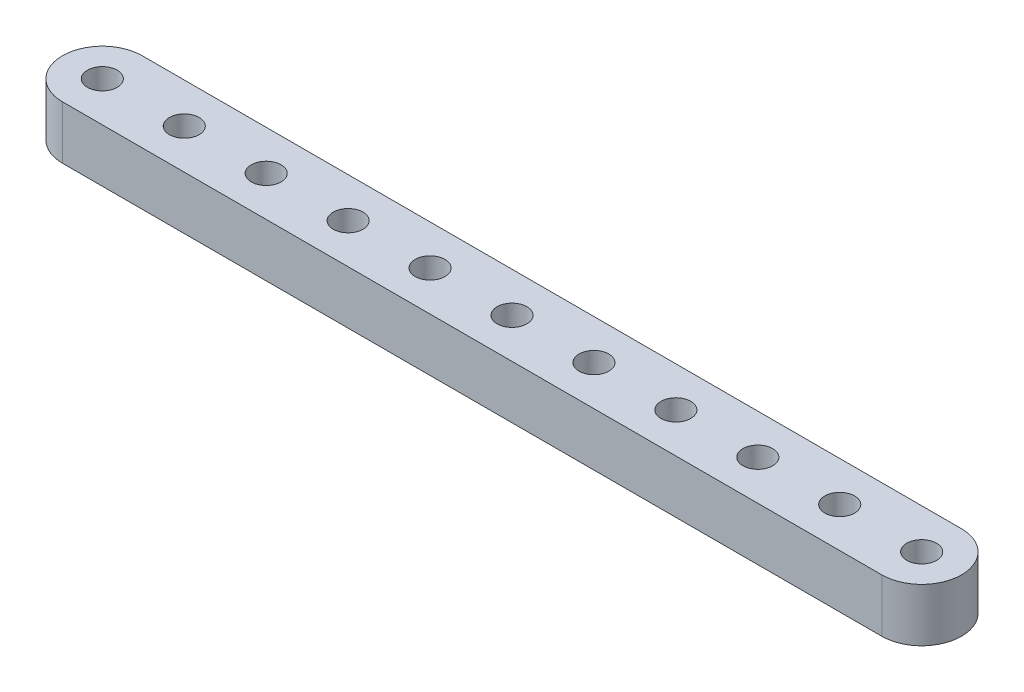
from build123d import *

# Parameters (mm, degrees)
SKETCH1_R           = 1.778
BOSS_EXTRUDE1_DEPTH = 6.35


with BuildPart() as part:
    # Sketch1 → Boss-Extrude1 (new body)
    with BuildSketch(Plane.XZ):
        with BuildLine():
            Line((-48.895, -4.7625), (48.895, -4.7625))
            ThreePointArc((48.895, -4.7625), (53.6575, 0), (48.895, 4.7625))
            Line((48.895, 4.7625), (-48.895, 4.7625))
            ThreePointArc((-48.895, 4.7625), (-53.6575, 0), (-48.895, -4.7625))
        make_face()
        with Locations((48.895, 0)):
            Circle(SKETCH1_R, mode=Mode.SUBTRACT)
        with Locations((39.116, 0)):
            Circle(SKETCH1_R, mode=Mode.SUBTRACT)
        with Locations((29.337, 0)):
            Circle(SKETCH1_R, mode=Mode.SUBTRACT)
        with Locations((19.558, 0)):
            Circle(SKETCH1_R, mode=Mode.SUBTRACT)
        with Locations((9.779, 0)):
            Circle(SKETCH1_R, mode=Mode.SUBTRACT)
        Circle(SKETCH1_R, mode=Mode.SUBTRACT)
        with Locations((-9.779, 0)):
            Circle(SKETCH1_R, mode=Mode.SUBTRACT)
        with Locations((-19.558, 0)):
            Circle(SKETCH1_R, mode=Mode.SUBTRACT)
        with Locations((-29.337, 0)):
            Circle(SKETCH1_R, mode=Mode.SUBTRACT)
        with Locations((-39.116, 0)):
            Circle(SKETCH1_R, mode=Mode.SUBTRACT)
        with Locations((-48.895, 0)):
            Circle(SKETCH1_R, mode=Mode.SUBTRACT)
    extrude(amount=-BOSS_EXTRUDE1_DEPTH)


solid = part.part
